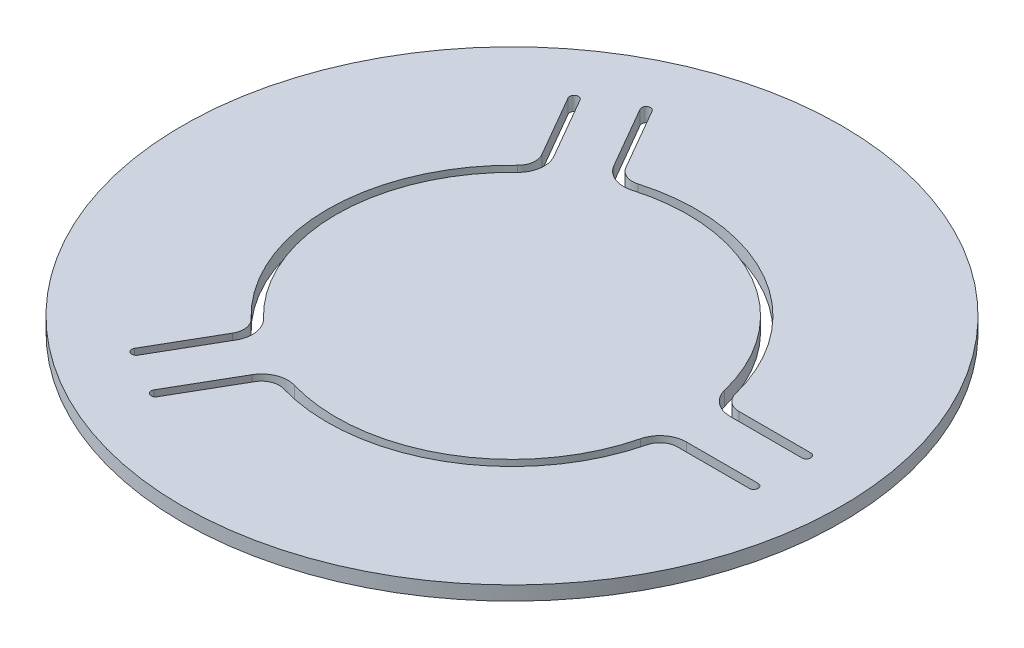
from build123d import *

# Parameters (mm, degrees)
SKETCH1_R           = 37.5
BOSS_EXTRUDE1_DEPTH = 0.8


with BuildPart() as part:
    # Sketch1 → Boss-Extrude1 (new body, symmetric)
    with BuildSketch(Plane(origin=(0, 0, 0), x_dir=(1, 0, 0), z_dir=(0, 1, 0))):
        Circle(SKETCH1_R)
        with BuildLine():
            ThreePointArc((-12.218911, 28.163775), (-12.901924, 28.346788), (-13.084936, 27.663775))
            Line((-13.084936, 27.663775), (-9.001292, 20.590695))
            ThreePointArc((-9.001292, 20.590695), (-7.523035, 19.307531), (-5.568014, 19.2093))
            ThreePointArc((-5.568014, 19.2093), (2.40884, 19.854407), (10, 17.320508))
            ThreePointArc((10, 17.320508), (15.990001, 12.01332), (19.419749, 4.782609))
            ThreePointArc((19.419749, 4.782609), (20.48233, 3.138626), (22.332711, 2.5))
            Line((22.332711, 2.5), (30.5, 2.5))
            ThreePointArc((30.5, 2.5), (31, 3), (30.5, 3.5))
            Line((30.5, 3.5), (22.332711, 3.5))
            ThreePointArc((22.332711, 3.5), (21.099124, 3.925751), (20.390737, 5.021739))
            ThreePointArc((20.390737, 5.021739), (16.789501, 12.613986), (10.5, 18.186533))
            ThreePointArc((10.5, 18.186533), (2.529282, 20.847128), (-5.846415, 20.169765))
            ThreePointArc((-5.846415, 20.169765), (-7.149762, 20.235252), (-8.135267, 21.090695))
            Line((-8.135267, 21.090695), (-12.218911, 28.163775))
        make_face(mode=Mode.SUBTRACT)
        with BuildLine():
            ThreePointArc((10.5, -18.186533), (16.789501, -12.613986), (20.390737, -5.021739))
            ThreePointArc((20.390737, -5.021739), (21.099124, -3.925751), (22.332711, -3.5))
            Line((22.332711, -3.5), (30.5, -3.5))
            ThreePointArc((30.5, -3.5), (31, -3), (30.5, -2.5))
            Line((30.5, -2.5), (22.332711, -2.5))
            ThreePointArc((22.332711, -2.5), (20.48233, -3.138626), (19.419749, -4.782609))
            ThreePointArc((19.419749, -4.782609), (15.990001, -12.01332), (10, -17.320508))
            ThreePointArc((10, -17.320508), (2.40884, -19.854407), (-5.568014, -19.2093))
            ThreePointArc((-5.568014, -19.2093), (-7.523035, -19.307531), (-9.001292, -20.590695))
            Line((-9.001292, -20.590695), (-13.084936, -27.663775))
            ThreePointArc((-13.084936, -27.663775), (-12.901924, -28.346788), (-12.218911, -28.163775))
            Line((-12.218911, -28.163775), (-8.135267, -21.090695))
            ThreePointArc((-8.135267, -21.090695), (-7.149762, -20.235252), (-5.846415, -20.169765))
            ThreePointArc((-5.846415, -20.169765), (2.529282, -20.847128), (10.5, -18.186533))
        make_face(mode=Mode.SUBTRACT)
        with BuildLine():
            ThreePointArc((-21, 0), (-19.318783, -8.233142), (-14.544322, -15.148026))
            ThreePointArc((-14.544322, -15.148026), (-13.949362, -16.309502), (-14.197445, -17.590695))
            Line((-14.197445, -17.590695), (-18.281089, -24.663775))
            ThreePointArc((-18.281089, -24.663775), (-18.098076, -25.346788), (-17.415064, -25.163775))
            Line((-17.415064, -25.163775), (-13.331419, -18.090695))
            ThreePointArc((-13.331419, -18.090695), (-12.959295, -16.168905), (-13.851735, -14.426692))
            ThreePointArc((-13.851735, -14.426692), (-18.398841, -7.841087), (-20, 0))
            ThreePointArc((-20, 0), (-18.398841, 7.841087), (-13.851735, 14.426692))
            ThreePointArc((-13.851735, 14.426692), (-12.959295, 16.168905), (-13.331419, 18.090695))
            Line((-13.331419, 18.090695), (-17.415064, 25.163775))
            ThreePointArc((-17.415064, 25.163775), (-18.098076, 25.346788), (-18.281089, 24.663775))
            Line((-18.281089, 24.663775), (-14.197445, 17.590695))
            ThreePointArc((-14.197445, 17.590695), (-13.949362, 16.309502), (-14.544322, 15.148026))
            ThreePointArc((-14.544322, 15.148026), (-19.318783, 8.233142), (-21, 0))
        make_face(mode=Mode.SUBTRACT)
    extrude(amount=BOSS_EXTRUDE1_DEPTH, both=True)


solid = part.part
